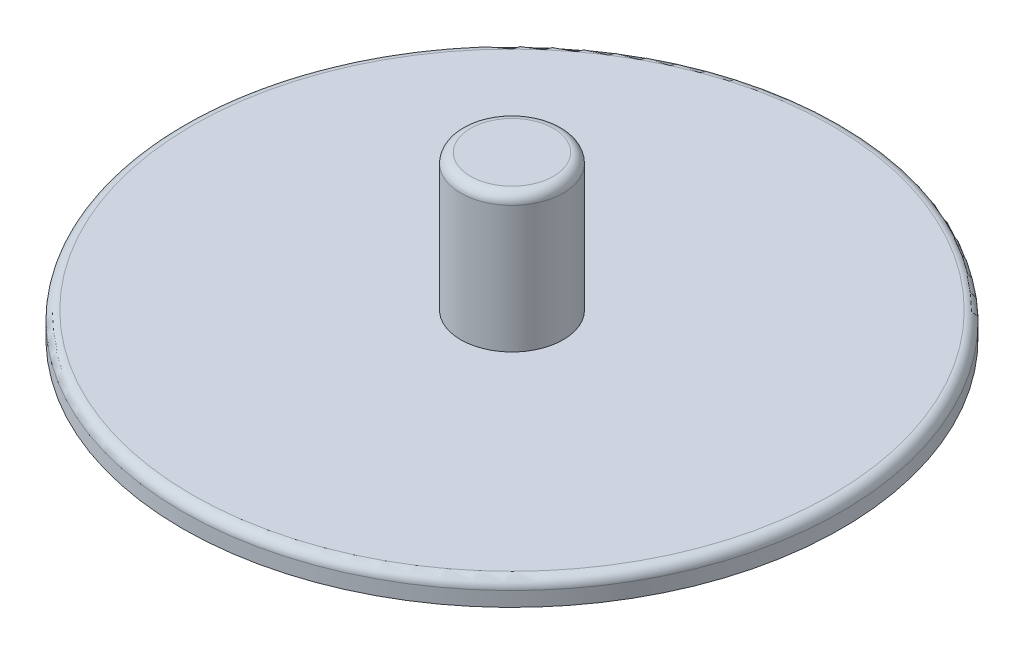
from build123d import *

# Parameters (mm, degrees)
SKETCH1_R           = 85.725
BOSS_EXTRUDE1_DEPTH = 6.35
SKETCH2_R           = 13.335
BOSS_EXTRUDE2_DEPTH = 35.56
FILLET1_R           = 2.54
FILLET2_R           = 2.54


with BuildPart() as part:
    # Sketch1 → Boss-Extrude1 (new body)
    with BuildSketch(Plane(origin=(0, 0, 0), x_dir=(1, 0, 0), z_dir=(0, 1, 0))):
        Circle(SKETCH1_R)
    extrude(amount=BOSS_EXTRUDE1_DEPTH)

    # Sketch2 → Boss-Extrude2 (add)
    with BuildSketch(Plane(origin=(0, 6.35, 0), x_dir=(1, 0, 0), z_dir=(0, 1, 0))):
        Circle(SKETCH2_R)
    extrude(amount=BOSS_EXTRUDE2_DEPTH)

    # Fillet1
    fillet1_edges = [part.edges().sort_by_distance(p)[0] for p in [
        (-13.335, 41.91, 0),
    ]]
    fillet(fillet1_edges, radius=FILLET1_R)

    # Fillet2
    fillet2_edges = [part.edges().sort_by_distance(p)[0] for p in [
        (-85.725, 6.35, 0),
    ]]
    fillet(fillet2_edges, radius=FILLET2_R)


solid = part.part
